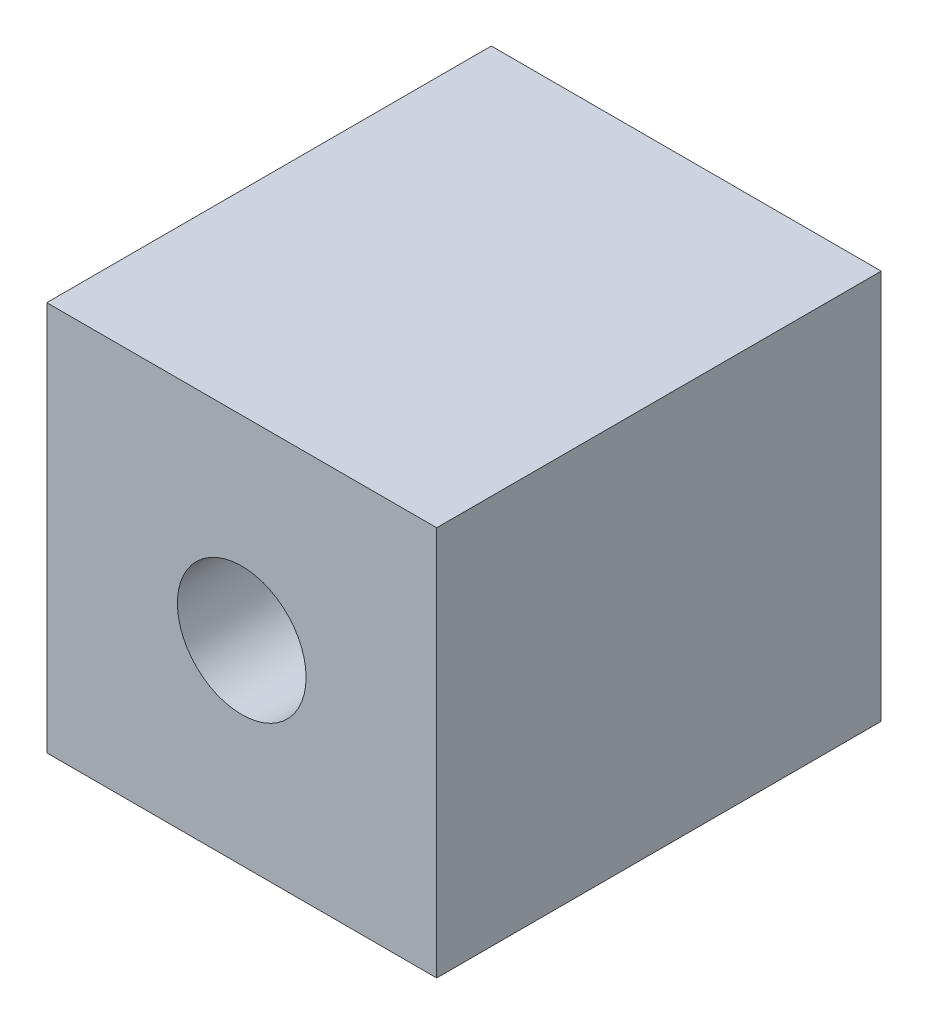
from build123d import *

# Parameters (mm, degrees)
SKETCH_1_W         = 10
SKETCH_1_H         = 10
EXTRUDE_1_DEPTH    = 11.4
HOLE_WIZARD_M4_1_D = 3.3


with BuildPart() as part:
    # 草图1 → 凸台-拉伸1 (new body)
    with BuildSketch(Plane.XY):
        with Locations((5, 5)):
            Rectangle(SKETCH_1_W, SKETCH_1_H)
    extrude(amount=EXTRUDE_1_DEPTH)

    # M4 螺纹孔1 (through all)
    with Locations(Plane.XY.offset(11.4)):
        with Locations((5, 5)):
            Hole(HOLE_WIZARD_M4_1_D / 2)


solid = part.part
